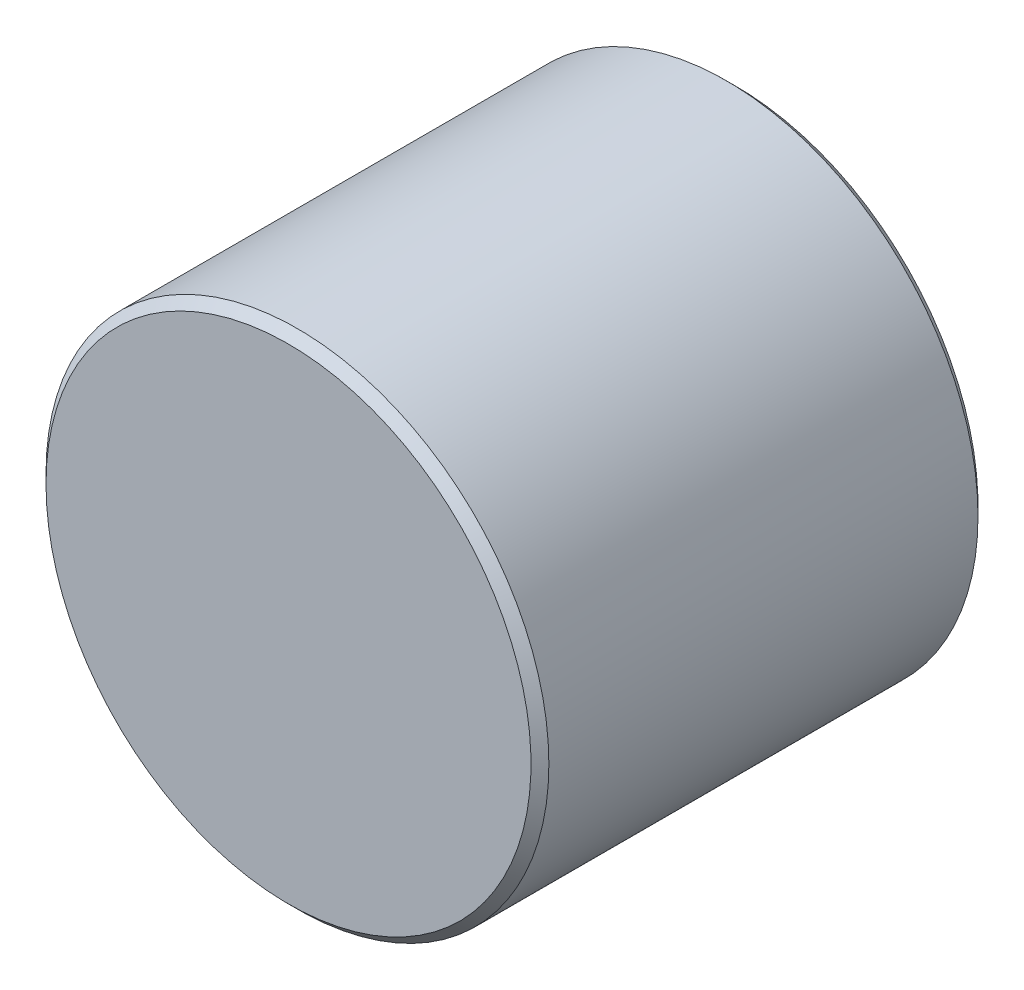
from build123d import *


with BuildPart() as part:
    # Sketch1 → Revolve1 (revolve)
    with BuildSketch(Plane.XZ):
        Polygon((6.88975, 12.7), (0, 12.7), (0, 0), (6.88975, 0), (7.14375, 0.254), (7.14375, 12.446), align=None)
    revolve(axis=Axis((0, 0, 12.7), (0, 0, -1)))


solid = part.part
